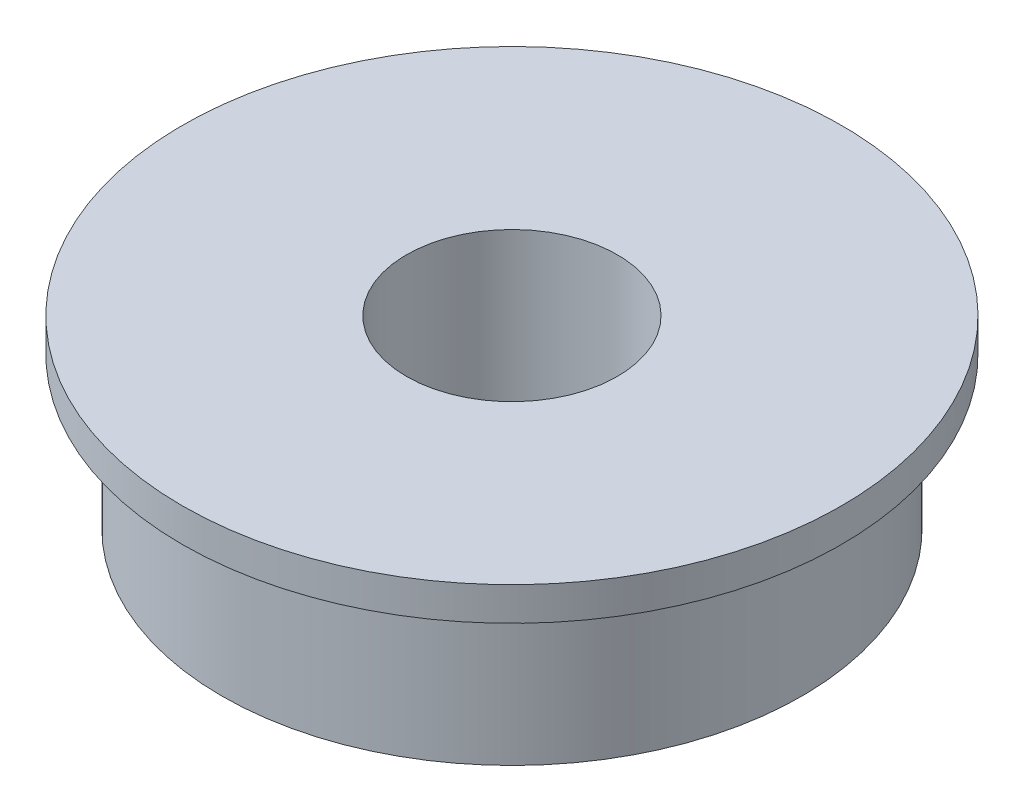
from build123d import *

# Parameters (mm, degrees)
SKETCH1_R           = 11
SKETCH1_R_2         = 4
BOSS_EXTRUDE1_DEPTH = 7
SKETCH2_R           = 12.5
SKETCH2_R_2         = 11
BOSS_EXTRUDE2_DEPTH = 1.27


with BuildPart() as part:
    # Sketch1 → Boss-Extrude1 (new body)
    with BuildSketch(Plane(origin=(0, 0, 0), x_dir=(1, 0, 0), z_dir=(0, 1, 0))):
        Circle(SKETCH1_R)
        Circle(SKETCH1_R_2, mode=Mode.SUBTRACT)
    extrude(amount=BOSS_EXTRUDE1_DEPTH)

    # Sketch2 → Boss-Extrude2 (add)
    with BuildSketch(Plane(origin=(0, 7, 0), x_dir=(1, 0, 0), z_dir=(0, 1, 0))):
        Circle(SKETCH2_R)
        Circle(SKETCH2_R_2, mode=Mode.SUBTRACT)
    extrude(amount=-BOSS_EXTRUDE2_DEPTH)


solid = part.part
